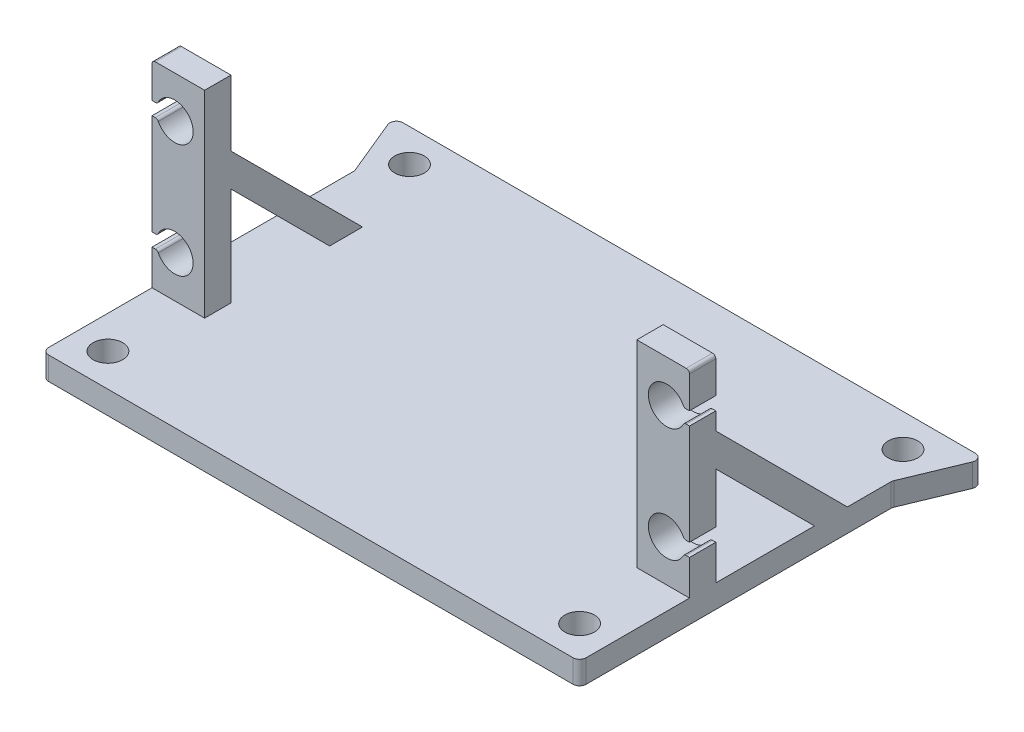
from build123d import *

# Parameters (mm, degrees)
SKETCH1_R           = 2.25
BOSS_EXTRUDE1_DEPTH = 3.5
SKETCH2_W           = 8
SKETCH2_H           = 4
BOSS_EXTRUDE2_DEPTH = 30
CUT_EXTRUDE1_DEPTH  = 41.8
BOSS_EXTRUDE3_DEPTH = 8
FILLET3_R           = 0.5
FILLET4_R           = 1


with BuildPart() as part:
    # Sketch1 → Boss-Extrude1 (new body)
    with BuildSketch(Plane(origin=(0, 0, 0), x_dir=(1, 0, 0), z_dir=(0, 1, 0))):
        Polygon((0, 0), (81.7, 0), (81.7, 47.5), (85.842135624, 57.5), (81.7, 57.5), (0, 57.5), (-4.142135624, 57.5), (0, 47.5), align=None)
        with Locations((5, 5)):
            Circle(SKETCH1_R, mode=Mode.SUBTRACT)
        with Locations((76.7, 5)):
            Circle(SKETCH1_R, mode=Mode.SUBTRACT)
        with Locations((3.34089319, 52.5)):
            Circle(SKETCH1_R, mode=Mode.SUBTRACT)
        with Locations((78.35910681, 52.5)):
            Circle(SKETCH1_R, mode=Mode.SUBTRACT)
    extrude(amount=BOSS_EXTRUDE1_DEPTH)

    # Sketch2 → Boss-Extrude2 (add)
    with BuildSketch(Plane(origin=(0, 3.5, 0), x_dir=(1, 0, 0), z_dir=(0, 1, 0))):
        with Locations((4, 18.7)):
            Rectangle(SKETCH2_W, SKETCH2_H)
        with Locations((77.7, 18.7)):
            Rectangle(SKETCH2_W, SKETCH2_H)
    extrude(amount=BOSS_EXTRUDE2_DEPTH)

    # Sketch3 → Cut-Extrude1 (cut, through all)
    with BuildSketch(Plane.XY.offset(-16.7)):
        with BuildLine():
            Line((0.834660634, 28.15), (0, 28.15))
            Line((0, 28.15), (0, 26.15))
            Line((0, 26.15), (0.834660634, 26.15))
            ThreePointArc((0.834660634, 26.15), (6.25, 27.15), (0.834660634, 28.15))
        make_face()
        with BuildLine():
            Line((0, 10.85), (0.834660634, 10.85))
            ThreePointArc((0.834660634, 10.85), (6.25, 9.85), (0.834660634, 8.85))
            Line((0.834660634, 8.85), (0, 8.85))
            Line((0, 8.85), (0, 10.85))
        make_face()
        with BuildLine():
            Line((81.7, 8.85), (81.7, 10.85))
            Line((81.7, 10.85), (80.865339366, 10.85))
            ThreePointArc((80.865339366, 10.85), (75.45, 9.85), (80.865339366, 8.85))
            Line((80.865339366, 8.85), (81.7, 8.85))
        make_face()
        with BuildLine():
            Line((81.7, 26.15), (80.865339366, 26.15))
            ThreePointArc((80.865339366, 26.15), (75.45, 27.15), (80.865339366, 28.15))
            Line((80.865339366, 28.15), (81.7, 28.15))
            Line((81.7, 28.15), (81.7, 26.15))
        make_face()
    extrude(amount=-CUT_EXTRUDE1_DEPTH, mode=Mode.SUBTRACT)

    # Sketch4 → Boss-Extrude3 (add)
    with BuildSketch(Plane(origin=(0, 0, 0), x_dir=(0, 0, -1), z_dir=(1, 0, 0))):
        Polygon((20.7, 23.5), (40.7, 3.5), (35.7, 3.5), (20.7, 18.5), align=None)
    boss_extrude3 = extrude(amount=BOSS_EXTRUDE3_DEPTH)

    # Mirror1: Boss-Extrude3 across plane
    add(boss_extrude3.mirror(Plane(origin=(40.85, 0, 0), x_dir=(0, 0, 1), z_dir=(1, 0, 0))))

    # Fillet3
    fillet3_edges = [part.edges().sort_by_distance(p)[0] for p in [
        (80.865339366, 26.15, -18.7),
        (80.865339366, 28.15, -18.7),
        (0.834660634, 10.85, -18.7),
        (0.834660634, 8.85, -18.7),
        (0, 33.5, -18.7),
        (81.7, 33.5, -18.7),
        (0.834660634, 28.15, -18.7),
        (0.834660634, 26.15, -18.7),
        (80.865339366, 8.85, -18.7),
        (80.865339366, 10.85, -18.7),
    ]]
    fillet(fillet3_edges, radius=FILLET3_R)

    # Fillet4
    fillet4_edges = [part.edges().sort_by_distance(p)[0] for p in [
        (0, 1.75, -47.5),
        (-4.142135624, 1.75, -57.5),
        (85.842135624, 1.75, -57.5),
        (81.7, 1.75, -47.5),
        (81.7, 1.75, 0),
        (0, 1.75, 0),
    ]]
    fillet(fillet4_edges, radius=FILLET4_R)


solid = part.part
